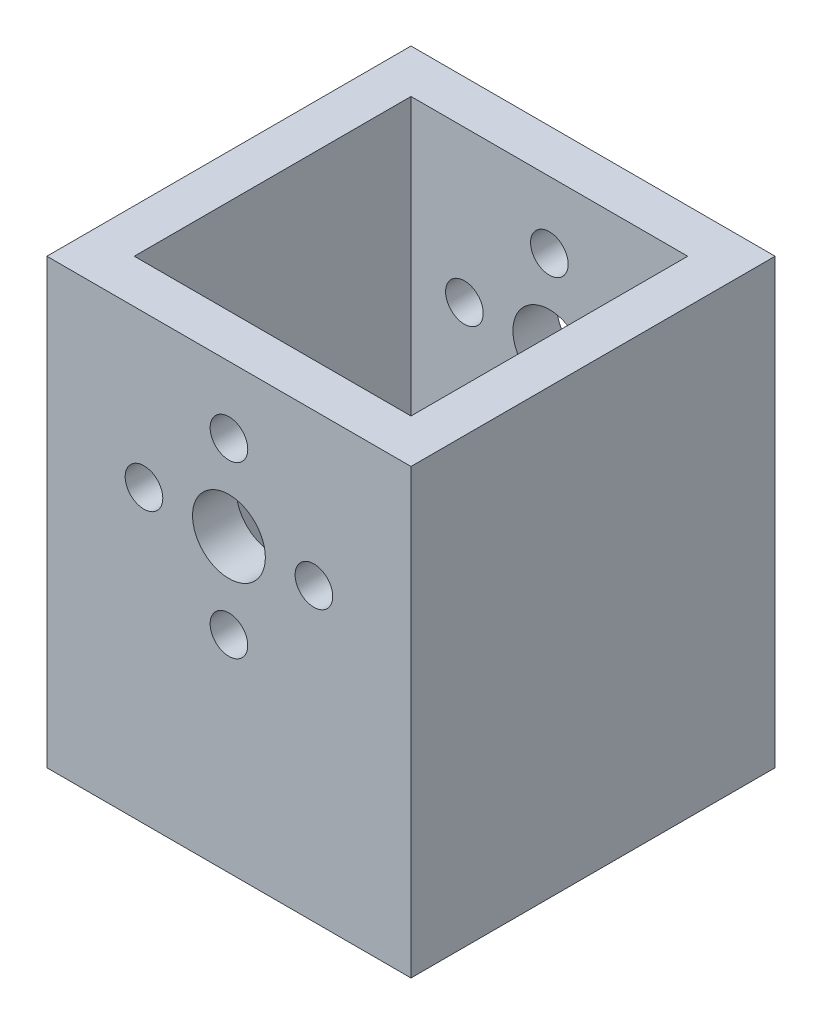
from build123d import *

# Parameters (mm, degrees)
SKETCH_1_R          = 3
SKETCH_1_R_2        = 1.55
EXTRUDE_1_DEPTH     = 30
CUT_EXTRUDE_1_DEPTH = 33.5


with BuildPart() as part:
    # 草图1 → 凸台-拉伸1 (new body)
    with BuildSketch(Plane.XY):
        Polygon((15, 0), (15, 12.5), (0, 12.5), (-15, 12.5), (-15, -24), (15, -24), align=None)
        Circle(SKETCH_1_R, mode=Mode.SUBTRACT)
        with Locations((0, 7)):
            Circle(SKETCH_1_R_2, mode=Mode.SUBTRACT)
        with Locations((7, 0)):
            Circle(SKETCH_1_R_2, mode=Mode.SUBTRACT)
        with Locations((0, -7)):
            Circle(SKETCH_1_R_2, mode=Mode.SUBTRACT)
        with Locations((-7, 0)):
            Circle(SKETCH_1_R_2, mode=Mode.SUBTRACT)
    extrude(amount=EXTRUDE_1_DEPTH)

    # 草图2 → 切除-拉伸1 (cut)
    with BuildSketch(Plane(origin=(0, 12.5, 0), x_dir=(1, 0, 0), z_dir=(0, 1, 0))):
        Polygon((-11.4, -15), (-11.4, -3.6), (0, -3.6), (11.4, -3.6), (11.4, -26.4), (0, -26.4), (-11.4, -26.4), align=None)
    extrude(amount=-CUT_EXTRUDE_1_DEPTH, mode=Mode.SUBTRACT)


solid = part.part
